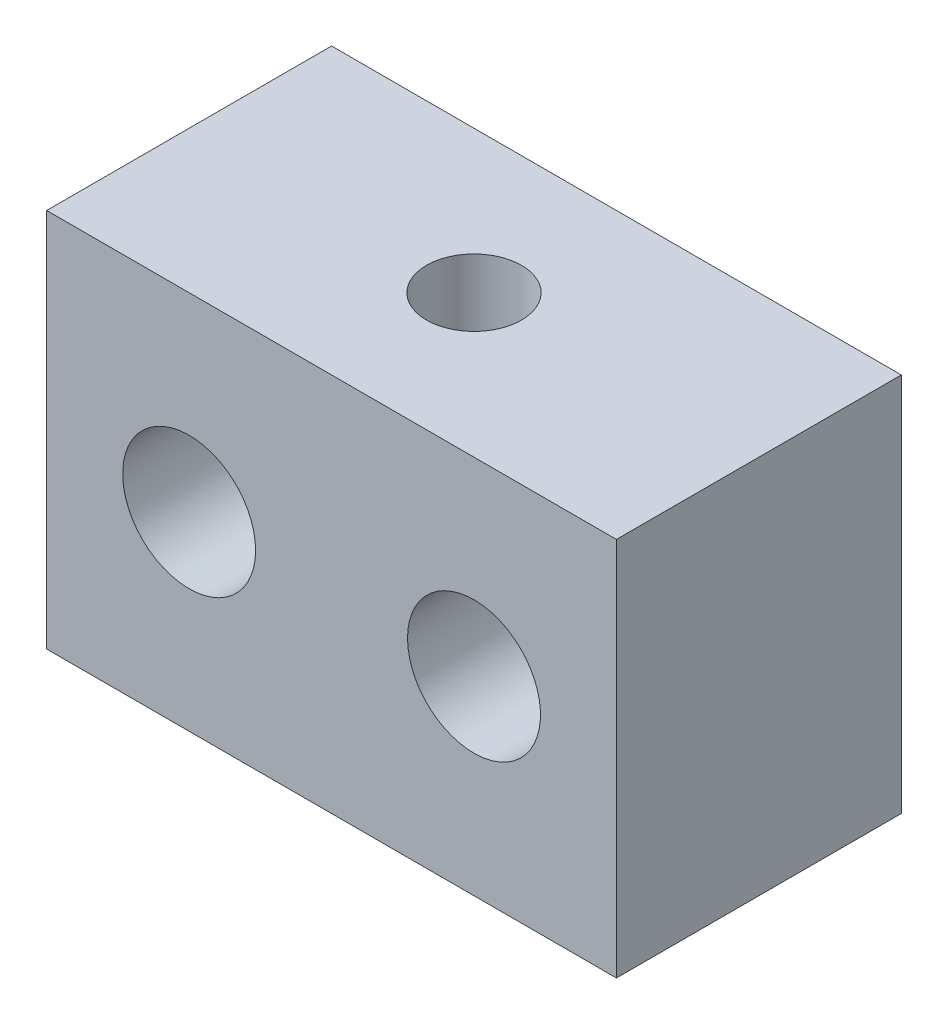
from build123d import *

# Parameters (mm, degrees)
SKETCH_1_W             = 30
SKETCH_1_H             = 20
SKETCH_1_R             = 3.5
EXTRUDE_1_DEPTH        = 15
HOLE_WIZARD_M6_1_D     = 5
HOLE_WIZARD_M6_1_DEPTH = 15
HOLE_WIZARD_M6_1_TIP   = 1.502151548


with BuildPart() as part:
    # 草图1 → 凸台-拉伸1 (new body)
    with BuildSketch(Plane.XY):
        Rectangle(SKETCH_1_W, SKETCH_1_H)
        with Locations((-7.5, 0)):
            Circle(SKETCH_1_R, mode=Mode.SUBTRACT)
        with Locations((7.5, 0)):
            Circle(SKETCH_1_R, mode=Mode.SUBTRACT)
    extrude(amount=EXTRUDE_1_DEPTH)

    # M6 螺纹孔1
    with Locations(Plane(origin=(0, 10, 7.5), x_dir=(0, 0, 1), z_dir=(0, 1, 0))):
        with Locations((0, 0)):
            Hole(HOLE_WIZARD_M6_1_D / 2, depth=HOLE_WIZARD_M6_1_DEPTH)
            with Locations((0, 0, -(HOLE_WIZARD_M6_1_DEPTH + HOLE_WIZARD_M6_1_TIP / 2))):  # 118° drill point
                Cone(0, HOLE_WIZARD_M6_1_D / 2, HOLE_WIZARD_M6_1_TIP, mode=Mode.SUBTRACT)


solid = part.part
